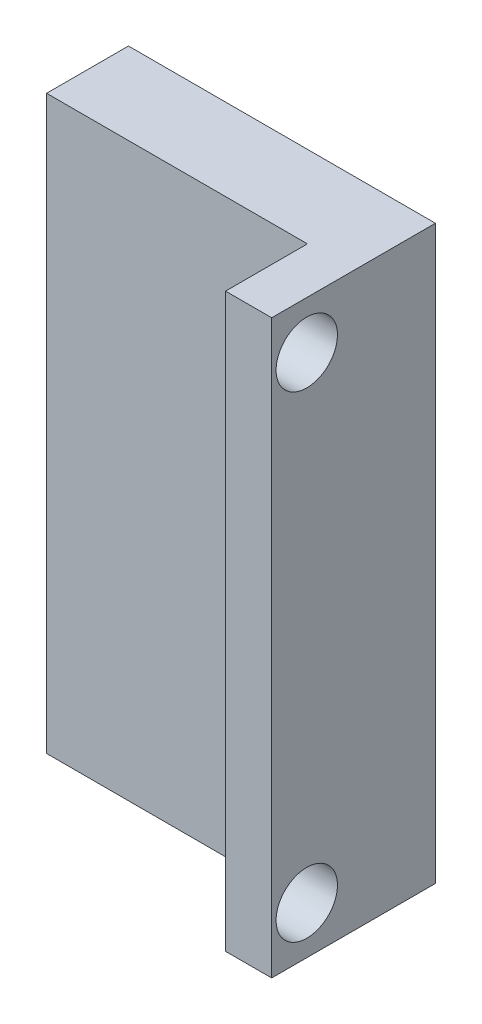
from build123d import *

# Parameters (mm, degrees)
SKETCH2_W           = 10
SKETCH2_H           = 10
BOSS_EXTRUDE1_DEPTH = 158.8
SKETCH3_R           = 3.5
BOSS_EXTRUDE2_DEPTH = 8
SKETCH4_W           = 15
SKETCH4_H           = 27.94
BOSS_EXTRUDE4_DEPTH = 4
SKETCH5_W           = 2.25448465
SKETCH5_H           = 27.94
BOSS_EXTRUDE5_DEPTH = 4
SKETCH6_R           = 1.5
CUT_EXTRUDE1_DEPTH  = 40
SKETCH7_W           = 23.127445718
SKETCH7_H           = 13.37135514
CUT_EXTRUDE2_DEPTH  = 158.8


with BuildPart() as part:
    # Sketch2 → Boss-Extrude1 (new body)
    with BuildSketch(Plane.XY):
        with Locations((5, 5)):
            Rectangle(SKETCH2_W, SKETCH2_H)
    extrude(amount=BOSS_EXTRUDE1_DEPTH)

    # Sketch3 → Boss-Extrude2 (add)
    with BuildSketch(Plane(origin=(10, 0, 0), x_dir=(0, 0, -1), z_dir=(1, 0, 0))):
        with Locations((-5, 5)):
            Circle(SKETCH3_R)
    extrude(amount=BOSS_EXTRUDE2_DEPTH)

    # Sketch4 → Boss-Extrude4 (add)
    with BuildSketch(Plane.XY.offset(158.8)):
        with Locations((7.5, 5)):
            Rectangle(SKETCH4_W, SKETCH4_H)
    extrude(amount=BOSS_EXTRUDE4_DEPTH)

    # Sketch5 → Boss-Extrude5 (add)
    with BuildSketch(Plane.XY.offset(162.8)):
        with Locations((13.872757675, 5)):
            Rectangle(SKETCH5_W, SKETCH5_H)
    extrude(amount=BOSS_EXTRUDE5_DEPTH)

    # Sketch6 → Cut-Extrude1 (cut)
    with BuildSketch(Plane.ZY.offset(-12.74551535)):
        with Locations((165.086, 16.64426)):
            Circle(SKETCH6_R)
        with Locations((165.086, -6.645)):
            Circle(SKETCH6_R)
    extrude(amount=-CUT_EXTRUDE1_DEPTH, mode=Mode.SUBTRACT)

    # Sketch7 → Cut-Extrude2 (cut)
    with BuildSketch(Plane(origin=(0, 0, 0), x_dir=(-1, 0, 0), z_dir=(0, 0, -1))):
        with Locations((-11.563722859, 6.68567757)):
            Rectangle(SKETCH7_W, SKETCH7_H)
    extrude(amount=-CUT_EXTRUDE2_DEPTH, mode=Mode.SUBTRACT)


solid = part.part
